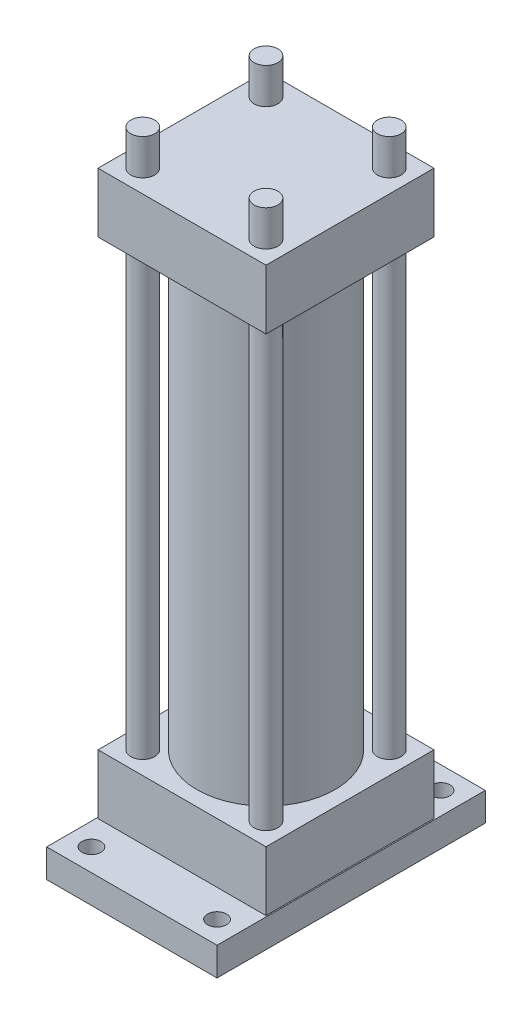
from build123d import *

# Parameters (mm, degrees)
CROQUIS1_W              = 114.3
CROQUIS1_H              = 180
SALIENTE_EXTRUIR1_DEPTH = 19.05
CROQUIS2_R              = 6.35
CORTAR_EXTRUIR1_DEPTH   = 19.05
CROQUIS3_W              = 112.7125
CROQUIS3_H              = 112.7125
SALIENTE_EXTRUIR2_DEPTH = 40
CROQUIS4_R              = 8
CORTAR_EXTRUIR2_DEPTH   = 40
CROQUIS5_R              = 8
SALIENTE_EXTRUIR3_DEPTH = 338
CROQUIS6_R              = 38.1
CORTAR_EXTRUIR3_DEPTH   = 10
CROQUIS7_R              = 46.355
SALIENTE_EXTRUIR4_DEPTH = 298
CROQUIS8_W              = 112.7125
CROQUIS8_H              = 112.7125
SALIENTE_EXTRUIR5_DEPTH = 40
CROQUIS9_R              = 8
SALIENTE_EXTRUIR6_DEPTH = 24


with BuildPart() as part:
    # Croquis1 → Saliente-Extruir1 (new body)
    with BuildSketch(Plane(origin=(0, 0, 0), x_dir=(1, 0, 0), z_dir=(0, 1, 0))):
        Rectangle(CROQUIS1_W, CROQUIS1_H)
    extrude(amount=SALIENTE_EXTRUIR1_DEPTH)

    # Croquis2 → Cortar-Extruir1 (cut)
    with BuildSketch(Plane(origin=(0, 19.05, 0), x_dir=(1, 0, 0), z_dir=(0, 1, 0))):
        with Locations((-42.15, 75)):
            Circle(CROQUIS2_R)
        with Locations((42.15, 75)):
            Circle(CROQUIS2_R)
        with Locations((42.15, -75)):
            Circle(CROQUIS2_R)
        with Locations((-42.15, -75)):
            Circle(CROQUIS2_R)
    extrude(amount=-CORTAR_EXTRUIR1_DEPTH, mode=Mode.SUBTRACT)

    # Croquis3 → Saliente-Extruir2 (add)
    with BuildSketch(Plane(origin=(0, 19.05, 0), x_dir=(1, 0, 0), z_dir=(0, 1, 0))):
        Rectangle(CROQUIS3_W, CROQUIS3_H)
    extrude(amount=SALIENTE_EXTRUIR2_DEPTH)

    # Croquis4 → Cortar-Extruir2 (cut)
    with BuildSketch(Plane(origin=(0, 59.05, 0), x_dir=(1, 0, 0), z_dir=(0, 1, 0))):
        with Locations((-41.35625, 41.35625)):
            Circle(CROQUIS4_R)
        with Locations((41.35625, 41.35625)):
            Circle(CROQUIS4_R)
        with Locations((41.35625, -41.35625)):
            Circle(CROQUIS4_R)
        with Locations((-41.35625, -41.35625)):
            Circle(CROQUIS4_R)
    extrude(amount=-CORTAR_EXTRUIR2_DEPTH, mode=Mode.SUBTRACT)

    # Croquis5 → Saliente-Extruir3 (add)
    with BuildSketch(Plane(origin=(0, 19.05, 0), x_dir=(1, 0, 0), z_dir=(0, 1, 0))):
        with Locations((-41.35625, 41.35625)):
            Circle(CROQUIS5_R)
        with Locations((41.35625, 41.35625)):
            Circle(CROQUIS5_R)
        with Locations((41.35625, -41.35625)):
            Circle(CROQUIS5_R)
        with Locations((-41.35625, -41.35625)):
            Circle(CROQUIS5_R)
    extrude(amount=SALIENTE_EXTRUIR3_DEPTH)

    # Croquis6 → Cortar-Extruir3 (cut)
    with BuildSketch(Plane(origin=(0, 59.05, 0), x_dir=(1, 0, 0), z_dir=(0, 1, 0))):
        Circle(CROQUIS6_R)
    extrude(amount=-CORTAR_EXTRUIR3_DEPTH, mode=Mode.SUBTRACT)

    # Croquis7 → Saliente-Extruir4 (add)
    with BuildSketch(Plane(origin=(0, 59.05, 0), x_dir=(1, 0, 0), z_dir=(0, 1, 0))):
        Circle(CROQUIS7_R)
    extrude(amount=SALIENTE_EXTRUIR4_DEPTH)

    # Croquis8 → Saliente-Extruir5 (add)
    with BuildSketch(Plane(origin=(0, 357.05, 0), x_dir=(1, 0, 0), z_dir=(0, 1, 0))):
        Rectangle(CROQUIS8_W, CROQUIS8_H)
    extrude(amount=SALIENTE_EXTRUIR5_DEPTH)

    # Croquis9 → Saliente-Extruir6 (add)
    with BuildSketch(Plane(origin=(0, 397.05, 0), x_dir=(1, 0, 0), z_dir=(0, 1, 0))):
        with Locations((-41.35625, 41.35625)):
            Circle(CROQUIS9_R)
        with Locations((41.35625, 41.35625)):
            Circle(CROQUIS9_R)
        with Locations((-41.35625, -41.35625)):
            Circle(CROQUIS9_R)
        with Locations((41.35625, -41.35625)):
            Circle(CROQUIS9_R)
    extrude(amount=SALIENTE_EXTRUIR6_DEPTH)


solid = part.part
